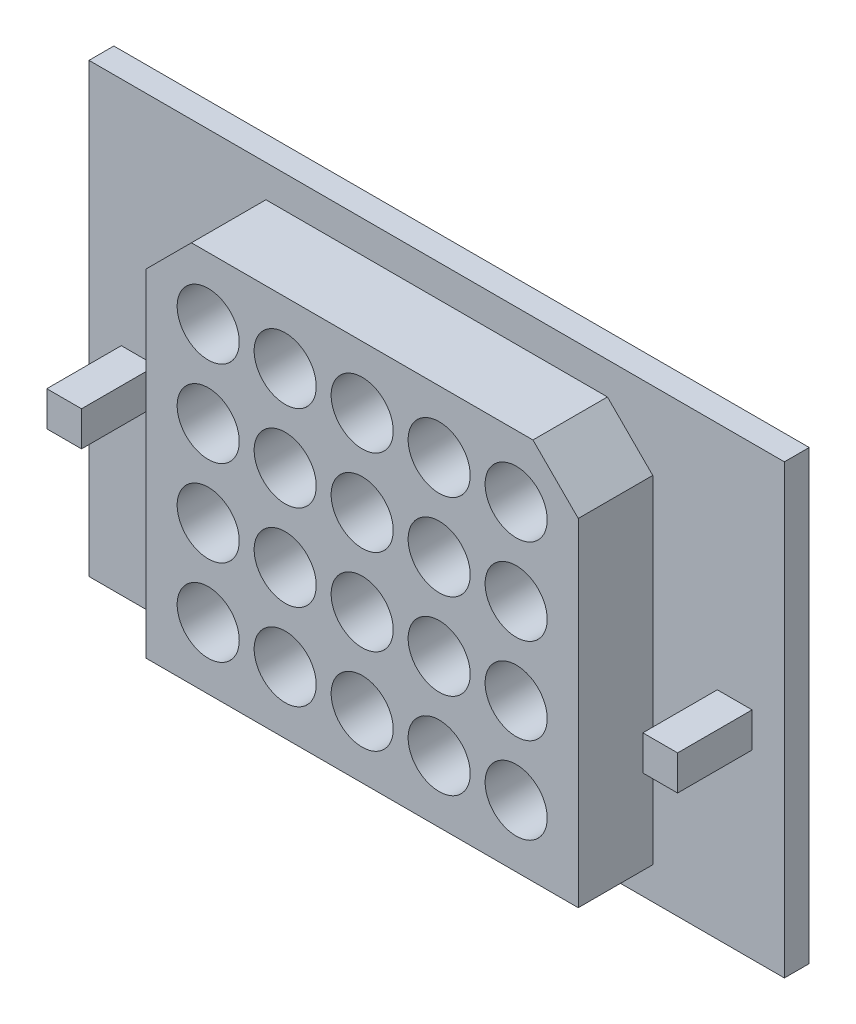
from build123d import *

# Parameters (mm, degrees)
SKETCH1_W           = 28
SKETCH1_H           = 18
BOSS_EXTRUDE1_DEPTH = 1
SKETCH2_W           = 1.4
SKETCH2_H           = 1.4
BOSS_EXTRUDE3_DEPTH = 3
SKETCH3_R           = 1.25
CUT_EXTRUDE1_DEPTH  = 10


with BuildPart() as part:
    # Sketch1 → Boss-Extrude1 (new body)
    with BuildSketch(Plane.XY):
        with Locations((-1.236641221, -1.241221374)):
            Rectangle(SKETCH1_W, SKETCH1_H)
    extrude(amount=BOSS_EXTRUDE1_DEPTH)

    # Sketch2 → Boss-Extrude3 (add)
    with BuildSketch(Plane.XY.offset(1)):
        with Locations((10.763358779, -2.241221374)):
            Rectangle(SKETCH2_W, SKETCH2_H)
        with Locations((-13.236641221, -2.241221374)):
            Rectangle(SKETCH2_W, SKETCH2_H)
        Polygon((-8.112377153, 6.458778626), (5.63909471, 6.458778626), (7.463358779, 4.634514557), (7.463358779, -8.941221374), (-9.936641221, -8.941221374), (-9.936641221, 4.634514557), align=None)
    extrude(amount=BOSS_EXTRUDE3_DEPTH)

    # Sketch3 → Cut-Extrude1 (cut)
    with BuildSketch(Plane.XY.offset(4)):
        with Locations((-7.436641221, 3.958778626)):
            Circle(SKETCH3_R)
        with Locations((-4.336641221, 3.958778626)):
            Circle(SKETCH3_R)
        with Locations((-1.236641221, 3.958778626)):
            Circle(SKETCH3_R)
        with Locations((1.863358779, 3.958778626)):
            Circle(SKETCH3_R)
        with Locations((4.963358779, 3.958778626)):
            Circle(SKETCH3_R)
        with Locations((-4.336641221, 0.492111959)):
            Circle(SKETCH3_R)
        with Locations((-1.236641221, 0.492111959)):
            Circle(SKETCH3_R)
        with Locations((1.863358779, 0.492111959)):
            Circle(SKETCH3_R)
        with Locations((4.963358779, 0.492111959)):
            Circle(SKETCH3_R)
        with Locations((-4.336641221, -2.974554707)):
            Circle(SKETCH3_R)
        with Locations((-1.236641221, -2.974554707)):
            Circle(SKETCH3_R)
        with Locations((1.863358779, -2.974554707)):
            Circle(SKETCH3_R)
        with Locations((4.963358779, -2.974554707)):
            Circle(SKETCH3_R)
        with Locations((-4.336641221, -6.441221374)):
            Circle(SKETCH3_R)
        with Locations((-1.236641221, -6.441221374)):
            Circle(SKETCH3_R)
        with Locations((1.863358779, -6.441221374)):
            Circle(SKETCH3_R)
        with Locations((4.963358779, -6.441221374)):
            Circle(SKETCH3_R)
        with Locations((-7.436641221, 0.492111959)):
            Circle(SKETCH3_R)
        with Locations((-7.436641221, -2.974554707)):
            Circle(SKETCH3_R)
        with Locations((-7.436641221, -6.441221374)):
            Circle(SKETCH3_R)
    extrude(amount=-CUT_EXTRUDE1_DEPTH, mode=Mode.SUBTRACT)


solid = part.part
